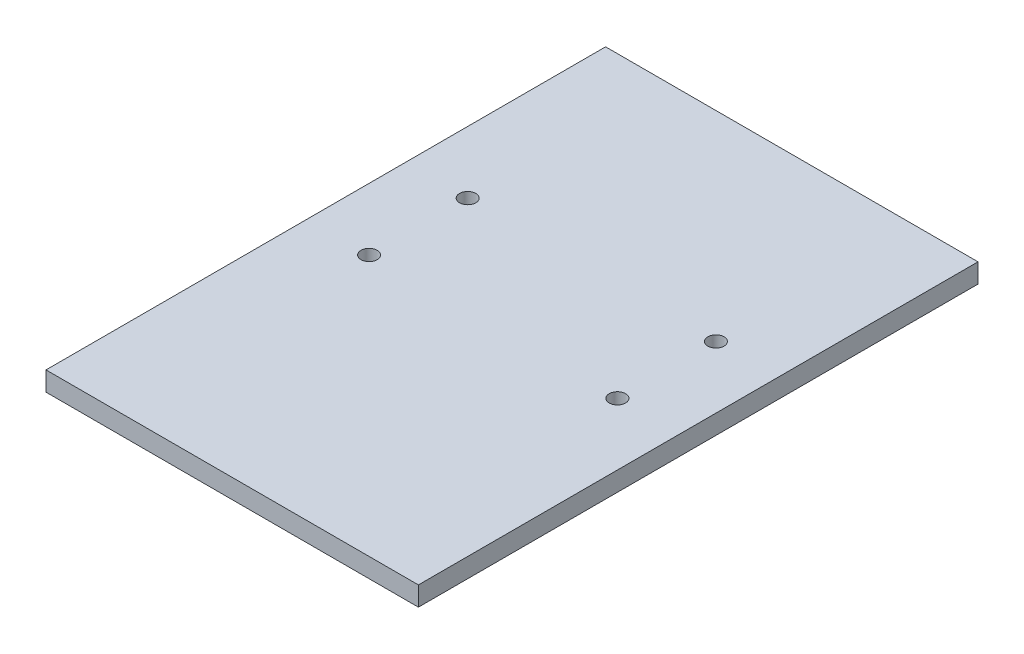
from build123d import *

# Parameters (mm, degrees)
SKETCH1_W                              = 240.03
SKETCH1_H                              = 360.68
BOSS_EXTRUDE1_DEPTH                    = 12.446
TAP_DRILL_FOR_M10_HELICOIL1_AT_2_COUNT = 2
TAP_DRILL_FOR_M10_HELICOIL1_AT_2_PITCH = 63.5


with BuildPart() as part:
    # Sketch1 → Boss-Extrude1 (new body)
    with BuildSketch(Plane(origin=(0, 0, 0), x_dir=(1, 0, 0), z_dir=(0, 1, 0))):
        Rectangle(SKETCH1_W, SKETCH1_H)
    extrude(amount=BOSS_EXTRUDE1_DEPTH)

    # Sketch4 → Tap Drill for M10 Helicoil1 (revolve, cut)
    with BuildSketch(Plane(origin=(80.01, 12.446, -51.435), x_dir=(0, 0, 1), z_dir=(1, 0, 0))):
        Polygon((0, 0), (0, 28.15451905), (5.25, 25.0000008), (5.25, 0), align=None)
    tap_drill_for_m10_helicoil1 = revolve(axis=Axis((80.01, 18.796, -51.435), (0, -1, 0)), mode=Mode.SUBTRACT)

    # Tap Drill for M10 Helicoil1 at 2: Tap Drill for M10 Helicoil1 ×2
    with Locations(*[(0, 0, i * TAP_DRILL_FOR_M10_HELICOIL1_AT_2_PITCH) for i in range(1, TAP_DRILL_FOR_M10_HELICOIL1_AT_2_COUNT)]):
        add(tap_drill_for_m10_helicoil1, mode=Mode.SUBTRACT)

    # Mirror1: Tap Drill for M10 Helicoil1 across plane
    add(tap_drill_for_m10_helicoil1.mirror(Plane.ZY), mode=Mode.SUBTRACT)

    # Mirror1 copy 1 sketch → Mirror1 copy 1 (revolve, cut)
    with BuildSketch(Plane(origin=(-80.01, 12.446, 12.065), x_dir=(0, 0, 1), z_dir=(-1, 0, 0))):
        Polygon((0, 0), (0, -28.15451905), (5.25, -25.0000008), (5.25, 0), align=None)
    revolve(axis=Axis((-80.01, 18.796, 12.065), (0, 1, 0)), mode=Mode.SUBTRACT)


solid = part.part
